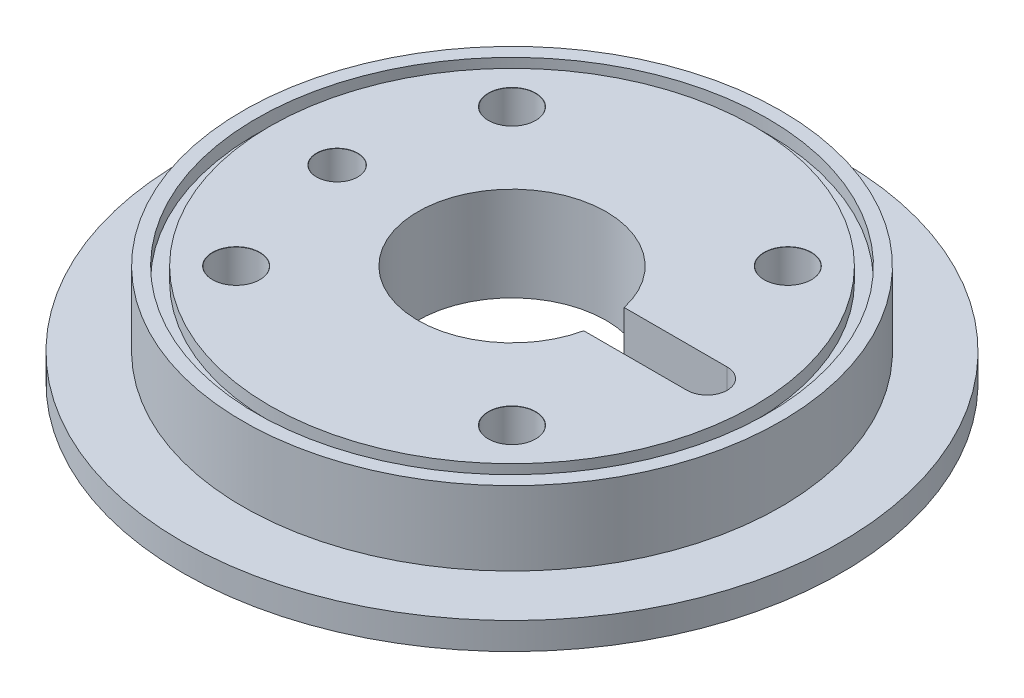
from build123d import *

# Parameters (mm, degrees)
CUT_EXTRUDE1_DEPTH                   = 8
M6_CLEARANCE_HOLE1_D                 = 7
M6_CLEARANCE_HOLE1_DEPTH             = 14
M6_CLEARANCE_HOLE1_CSINK_D           = 7.05
M6_CLEARANCE_HOLE1_CSINK_ANGLE       = 90
CIRPATTERN1_COUNT                    = 4
F_6_1_6_1_DIAMETER_HOLE1_D           = 6.1
F_6_1_6_1_DIAMETER_HOLE1_DEPTH       = 14
F_6_1_6_1_DIAMETER_HOLE1_CSINK_D     = 6.15
F_6_1_6_1_DIAMETER_HOLE1_CSINK_ANGLE = 90


with BuildPart() as part:
    # Sketch1 → Revolve1 (revolve)
    with BuildSketch(Plane.XY):
        Polygon((-14, 1), (-14, 15), (-36, 15), (-36, 13), (-38, 13), (-38, 15), (-40, 15), (-40, 4), (-49, 4), (-49, 0), (-47, 0), (-47, 2), (-45, 2), (-45, 0), (-43, 0), (-43, 1), align=None)
    revolve(axis=Axis((0, 0, 0), (0, 1, 0)))

    # Sketch2 → Cut-Extrude1 (cut)
    with BuildSketch(Plane(origin=(0, 15, 0), x_dir=(1, 0, 0), z_dir=(0, 1, 0))):
        with BuildLine():
            Line((0, 3), (29, 3))
            ThreePointArc((29, 3), (32, 0), (29, -3))
            Line((29, -3), (0, -3))
            ThreePointArc((0, -3), (-3, 0), (0, 3))
        make_face()
    extrude(amount=-CUT_EXTRUDE1_DEPTH, mode=Mode.SUBTRACT)

    # M6 Clearance Hole1
    with Locations(Plane(origin=(0, 15, 0), x_dir=(1, 0, 0), z_dir=(0, 1, 0))):
        with Locations((20.506096654, 20.506096654)):
            m6_clearance_hole1 = CounterSinkHole(M6_CLEARANCE_HOLE1_D / 2, M6_CLEARANCE_HOLE1_CSINK_D / 2, depth=M6_CLEARANCE_HOLE1_DEPTH, counter_sink_angle=M6_CLEARANCE_HOLE1_CSINK_ANGLE)

    # CirPattern1: M6 Clearance Hole1 ×4 about axis
    cirpattern1_axis = Axis((0, 0, 0), (0, 1, 0))
    for i in range(1, CIRPATTERN1_COUNT):
        add(m6_clearance_hole1.rotate(cirpattern1_axis, i * 360 / CIRPATTERN1_COUNT), mode=Mode.SUBTRACT)

    # Ø6.1 (6.1) Diameter Hole1
    with Locations(Plane(origin=(0, 15, 0), x_dir=(1, 0, 0), z_dir=(0, 1, 0))):
        with Locations((-26, 0)):
            CounterSinkHole(F_6_1_6_1_DIAMETER_HOLE1_D / 2, F_6_1_6_1_DIAMETER_HOLE1_CSINK_D / 2, depth=F_6_1_6_1_DIAMETER_HOLE1_DEPTH, counter_sink_angle=F_6_1_6_1_DIAMETER_HOLE1_CSINK_ANGLE)


solid = part.part
